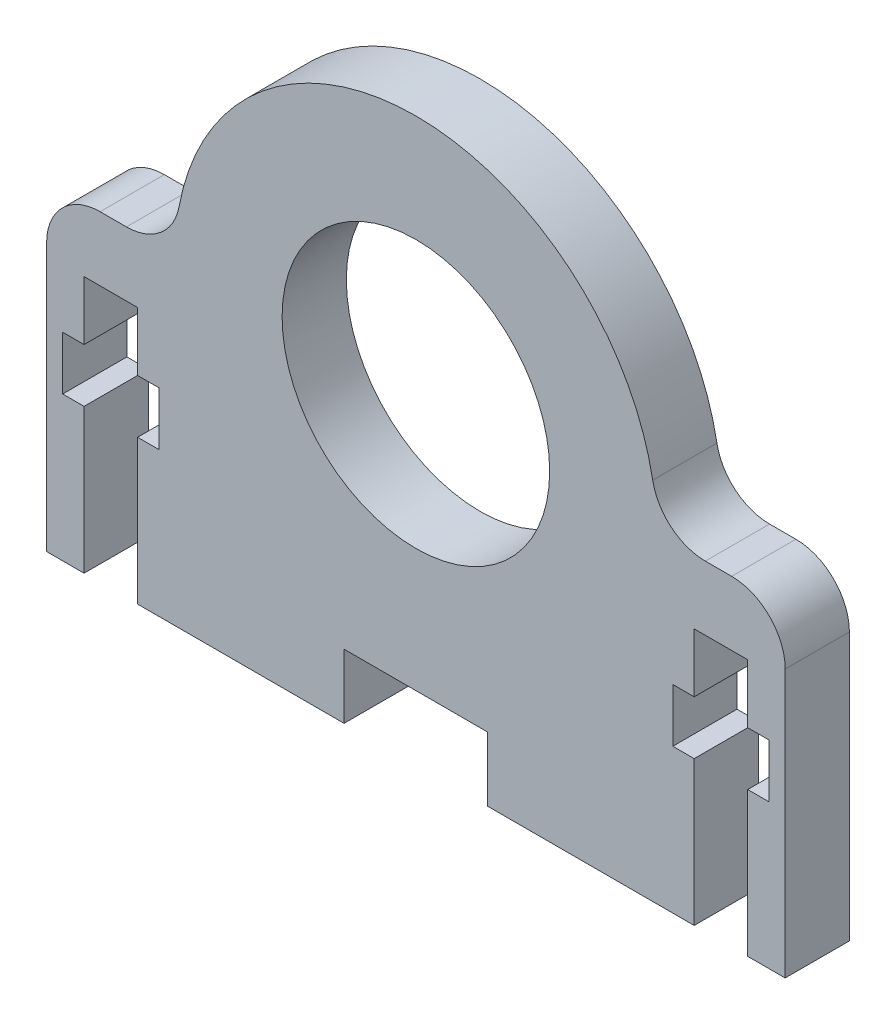
from build123d import *

# Parameters (mm, degrees)
SKETCH1_R           = 12.5
BOSS_EXTRUDE1_DEPTH = 6
BOSS_EXTRUDE2_DEPTH = 6
FILLET1_R           = 5


with BuildPart() as part:
    # Sketch1 → Boss-Extrude1 (new body)
    with BuildSketch(Plane.XY):
        with BuildLine():
            Line((-22.5, 0), (-22.5, -30))
            Line((-22.5, -30), (-6.707199182, -30))
            Line((-6.707199182, -30), (-6.707199182, -24))
            Line((-6.707199182, -24), (6.707199182, -24))
            Line((6.707199182, -24), (6.707199182, -30))
            Line((6.707199182, -30), (22.5, -30))
            Line((22.5, -30), (22.5, 0))
            ThreePointArc((22.5, 0), (0, 22.5), (-22.5, 0))
        make_face()
        Circle(SKETCH1_R, mode=Mode.SUBTRACT)
    extrude(amount=BOSS_EXTRUDE1_DEPTH)

    # Sketch2 → Boss-Extrude2 (add)
    with BuildSketch(Plane.XY):
        Polygon((-22.5, -30), (-26, -30), (-26, -16.5), (-24, -16.5), (-24, -11.5), (-26, -11.5), (-26, -6), (-31, -6), (-31, -11.5), (-33, -11.5), (-33, -16.5), (-31, -16.5), (-31, -30), (-34.5, -30), (-34.5, 0), (-22.5, 0), align=None)
    boss_extrude2 = extrude(amount=BOSS_EXTRUDE2_DEPTH)

    # Mirror1: Boss-Extrude2 across plane
    add(boss_extrude2.mirror(Plane(origin=(0, 0, 0), x_dir=(0, 0, 1), z_dir=(1, 0, 0))))

    # Fillet1
    fillet1_edges = [part.edges().sort_by_distance(p)[0] for p in [
        (22.5, 0, 3),
        (-22.5, 0, 3),
        (-34.5, 0, 3),
        (34.5, 0, 3),
    ]]
    fillet(fillet1_edges, radius=FILLET1_R)


solid = part.part
